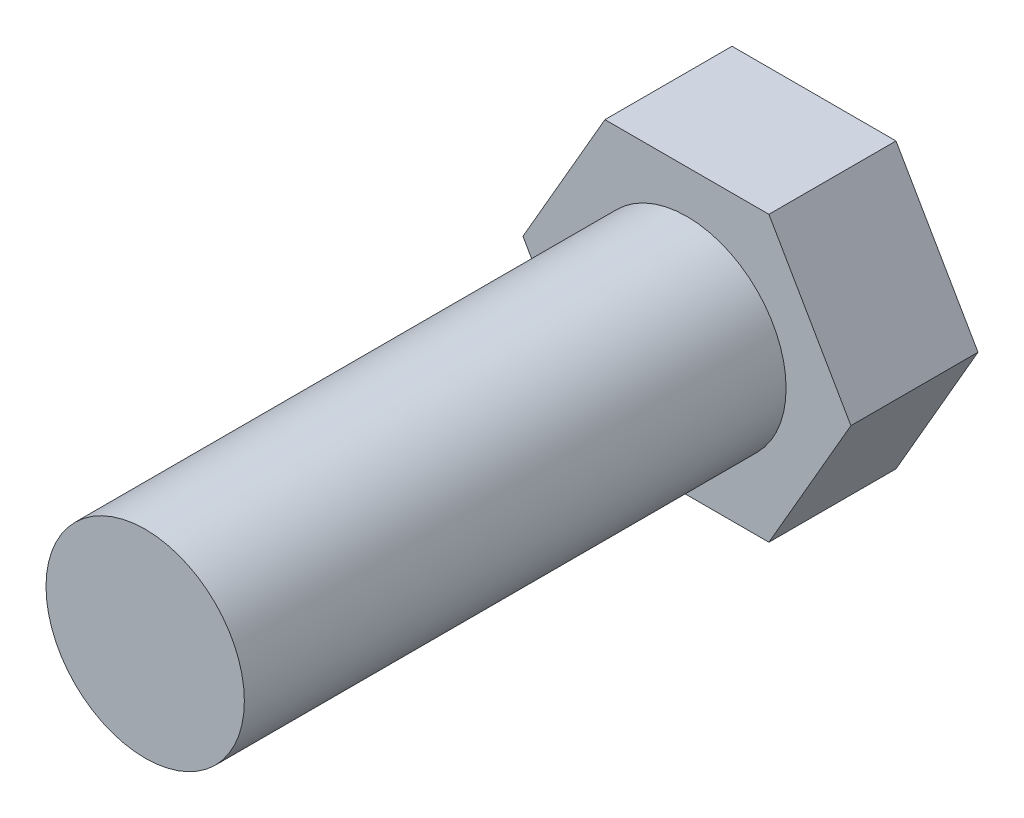
from build123d import *

# Parameters (mm, degrees)
BOSS_EXTRUDE1_DEPTH = 3.05
SKETCH2_R           = 2.38
BOSS_EXTRUDE2_DEPTH = 13


with BuildPart() as part:
    # Sketch1 → Boss-Extrude1 (new body)
    with BuildSketch(Plane.XY):
        Polygon((1.9675, -3.407809964), (3.935, 0), (1.9675, 3.407809964), (-1.9675, 3.407809964), (-3.935, 0), (-1.9675, -3.407809964), align=None)
    extrude(amount=BOSS_EXTRUDE1_DEPTH)

    # Sketch2 → Boss-Extrude2 (add)
    with BuildSketch(Plane.XY.offset(3.05)):
        Circle(SKETCH2_R)
    extrude(amount=BOSS_EXTRUDE2_DEPTH)


solid = part.part
